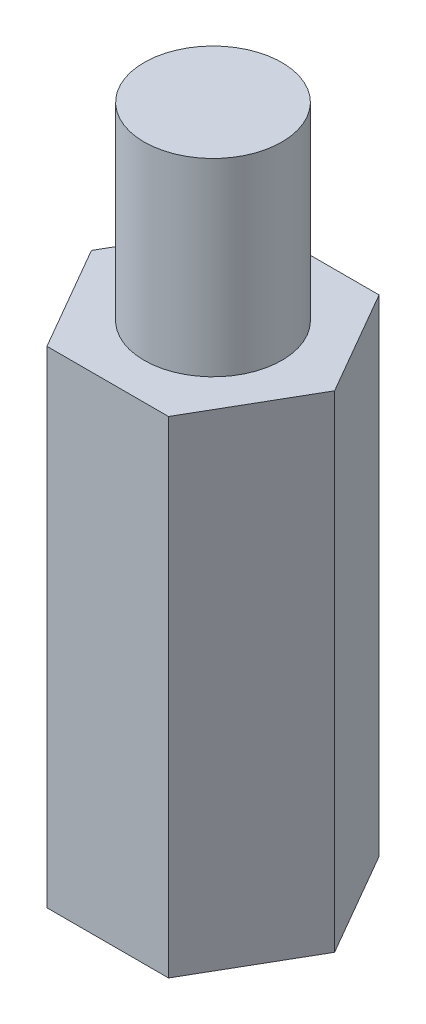
from build123d import *

# Parameters (mm, degrees)
SKETCH_1_R      = 2.5
EXTRUDE_1_DEPTH = 18
SKETCH_2_R      = 2.55
EXTRUDE_2_DEPTH = 7


with BuildPart() as part:
    # 草图1 → 凸台-拉伸1 (new body)
    with BuildSketch(Plane(origin=(0, 0, 0), x_dir=(1, 0, 0), z_dir=(0, 1, 0))):
        Polygon((4.5, 0), (2.25, 3.897114317), (-2.25, 3.897114317), (-4.5, 0), (-2.25, -3.897114317), (2.25, -3.897114317), align=None)
        Circle(SKETCH_1_R, mode=Mode.SUBTRACT)
    extrude(amount=EXTRUDE_1_DEPTH)

    # 草图2 → 凸台-拉伸2 (add)
    with BuildSketch(Plane(origin=(0, 18, 0), x_dir=(1, 0, 0), z_dir=(0, 1, 0))):
        Circle(SKETCH_2_R)
    extrude(amount=EXTRUDE_2_DEPTH)


solid = part.part
